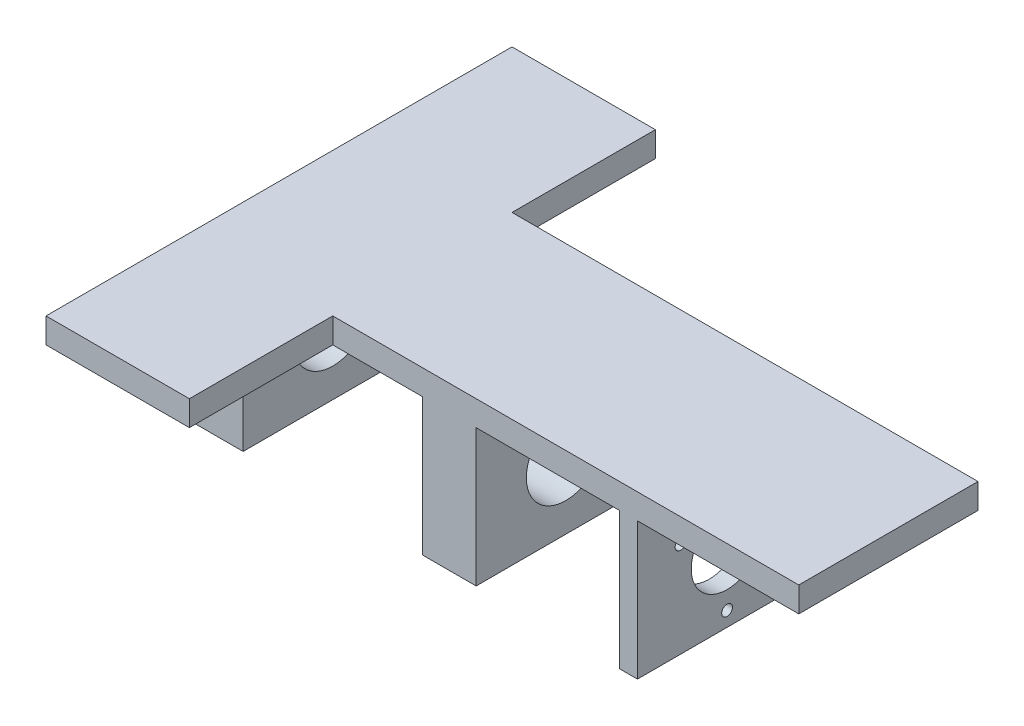
from build123d import *

# Parameters (mm, degrees)
BOSS_EXTRUDE2_DEPTH = 7
SKETCH2_W           = 15
SKETCH2_H           = 50
SKETCH2_W_2         = 5
BOSS_EXTRUDE4_DEPTH = 38.25
SKETCH10_R          = 11
CUT_EXTRUDE5_DEPTH  = 15
SKETCH11_R          = 11
CUT_EXTRUDE7_DEPTH  = 15
SKETCH23_R          = 10
SKETCH23_R_2        = 1.5
CUT_EXTRUDE10_DEPTH = 5
SKETCH12_R          = 10
SKETCH12_R_2        = 1.5
CUT_EXTRUDE9_DEPTH  = 5


with BuildPart() as part:
    # Sketch1 → Boss-Extrude2 (new body)
    with BuildSketch(Plane(origin=(0, 0, 0), x_dir=(1, 0, 0), z_dir=(0, 1, 0))):
        Polygon((40, 0), (170, 0), (170, 50), (40, 50), (40, 90), (0, 90), (0, 50), (0, 0), (0, -40), (40, -40), align=None)
    extrude(amount=BOSS_EXTRUDE2_DEPTH)

    # Sketch2 → Boss-Extrude4 (add)
    with BuildSketch(Plane.XZ):
        with Locations((7.5, -25)):
            Rectangle(SKETCH2_W, SKETCH2_H)
        with Locations((72.5, -25)):
            Rectangle(SKETCH2_W, SKETCH2_H)
        with Locations((122.5, -25)):
            Rectangle(SKETCH2_W_2, SKETCH2_H)
    extrude(amount=BOSS_EXTRUDE4_DEPTH)

    # Sketch10 → Cut-Extrude5 (cut)
    with BuildSketch(Plane.ZY):
        with Locations((-25, -19.125)):
            Circle(SKETCH10_R)
    extrude(amount=-CUT_EXTRUDE5_DEPTH, mode=Mode.SUBTRACT)

    # Sketch11 → Cut-Extrude7 (cut)
    with BuildSketch(Plane.ZY.offset(-65)):
        with Locations((-25, -19.125)):
            Circle(SKETCH11_R)
    extrude(amount=-CUT_EXTRUDE7_DEPTH, mode=Mode.SUBTRACT)

    # Sketch23 → Cut-Extrude10 (cut)
    with BuildSketch(Plane(origin=(125, 0, 0), x_dir=(0, 0, -1), z_dir=(1, 0, 0))):
        with Locations((25, -19.125)):
            Circle(SKETCH23_R)
        with Locations((12.009618943, -11.625)):
            Circle(SKETCH23_R_2)
        with Locations((37.990381057, -11.625)):
            Circle(SKETCH23_R_2)
        with Locations((25, -34.125)):
            Circle(SKETCH23_R_2)
    extrude(amount=-CUT_EXTRUDE10_DEPTH, mode=Mode.SUBTRACT)

    # Sketch12 → Cut-Extrude9 (cut)
    with BuildSketch(Plane(origin=(125, 0, 0), x_dir=(0, 0, -1), z_dir=(1, 0, 0))):
        with Locations((25, -19.125)):
            Circle(SKETCH12_R)
        with Locations((12.009618943, -11.625)):
            Circle(SKETCH12_R_2)
        with Locations((37.990381057, -11.625)):
            Circle(SKETCH12_R_2)
        with Locations((25, -34.125)):
            Circle(SKETCH12_R_2)
    extrude(amount=-CUT_EXTRUDE9_DEPTH, mode=Mode.SUBTRACT)


solid = part.part
